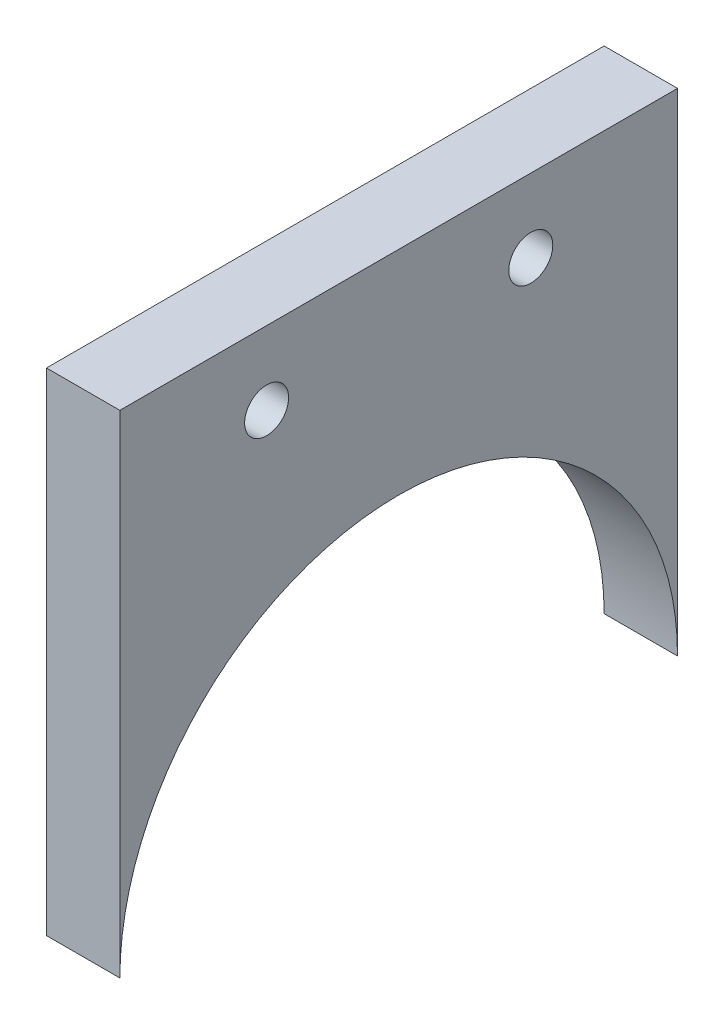
from build123d import *

# Parameters (mm, degrees)
SCHIZZO1_W                   = 38
SCHIZZO1_H                   = 33.5
ESTRUSIONE_ESTRUSIONE1_DEPTH = 5
SCHIZZO2_R                   = 19
SCHIZZO2_R_2                 = 1.5
TAGLIO_ESTRUSIONE1_DEPTH     = 6


with BuildPart() as part:
    # Schizzo1 → Estrusione-Estrusione1 (new body)
    with BuildSketch(Plane(origin=(0, 0, 0), x_dir=(0, 0, -1), z_dir=(1, 0, 0))):
        Rectangle(SCHIZZO1_W, SCHIZZO1_H)
    extrude(amount=ESTRUSIONE_ESTRUSIONE1_DEPTH)

    # Schizzo2 → Taglio-Estrusione1 (cut, through all)
    with BuildSketch(Plane(origin=(0, 0, 0), x_dir=(0, 0, -1), z_dir=(1, 0, 0))):
        with Locations((0, -16.75)):
            Circle(SCHIZZO2_R)
        with Locations((-9, 11.75)):
            Circle(SCHIZZO2_R_2)
        with Locations((9, 11.75)):
            Circle(SCHIZZO2_R_2)
    extrude(amount=TAGLIO_ESTRUSIONE1_DEPTH, mode=Mode.SUBTRACT)


solid = part.part
